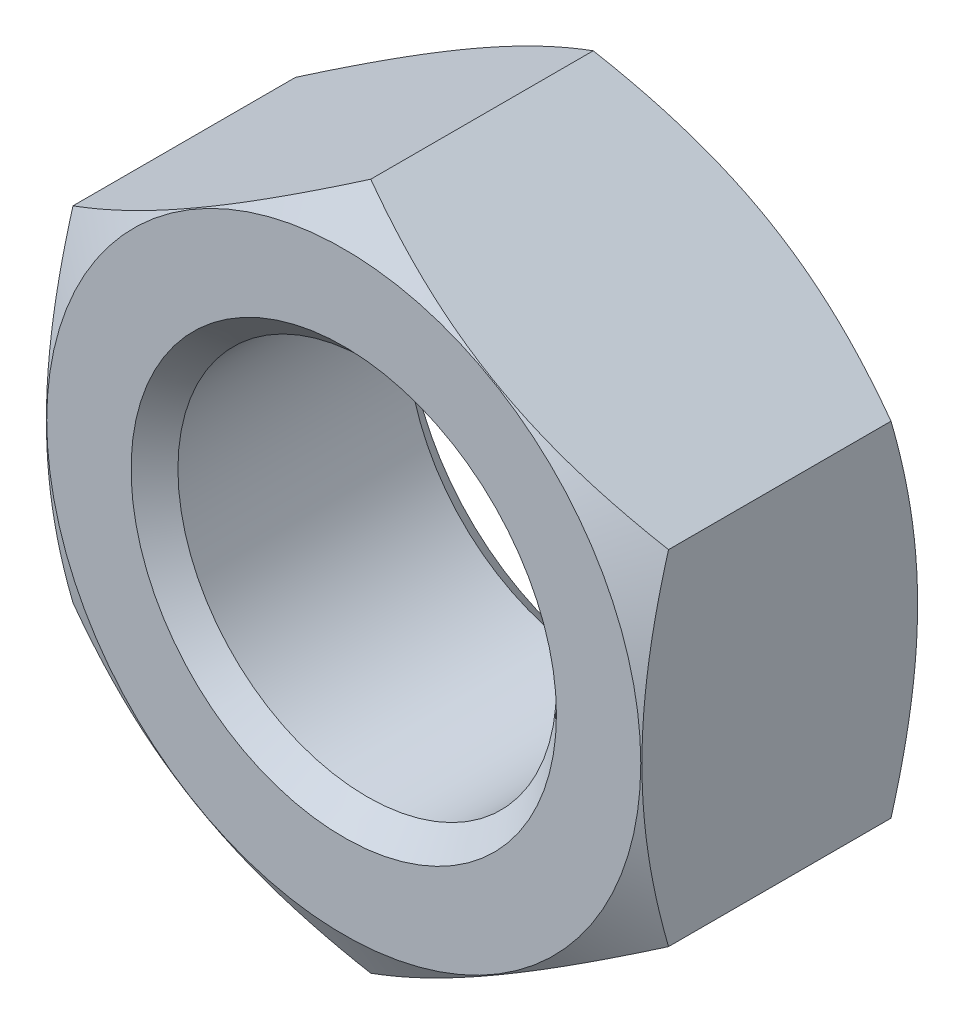
from build123d import *

# Parameters (mm, degrees)
SKETCH_1_R      = 8.8985
EXTRUDE_1_DEPTH = 13
CHAMFER_1_SIZE  = 1.1015


with BuildPart() as part:
    # Эскиз1 → Бобышка-Вытянуть1 (new body)
    with BuildSketch(Plane.XY):
        Polygon((0, 16.165807537), (-14, 8.082903769), (-14, -8.082903769), (0, -16.165807537), (14, -8.082903769), (14, 8.082903769), align=None)
        Circle(SKETCH_1_R, mode=Mode.SUBTRACT)
    extrude(amount=-EXTRUDE_1_DEPTH)

    # Эскиз2 → Вырез-Повернуть1 (revolve, cut)
    with BuildSketch(Plane(origin=(0, 0, 0), x_dir=(0, 0, -1), z_dir=(1, 0, 0))):
        Polygon((0, 13.965807537), (5.773502692, 23.965807537), (0, 23.965807537), align=None)
        Polygon((13, 23.965807537), (13, 13.965807537), (7.226497308, 23.965807537), align=None)
    revolve(axis=Axis((0, 0, 0), (0, 0, 1)), mode=Mode.SUBTRACT)

    # Фаска1
    chamfer_1_edges = [part.edges().sort_by_distance(p)[0] for p in [
        (-8.8985, 0, -13),
        (-8.8985, 0, 0),
    ]]
    chamfer(chamfer_1_edges, length=CHAMFER_1_SIZE)


solid = part.part
